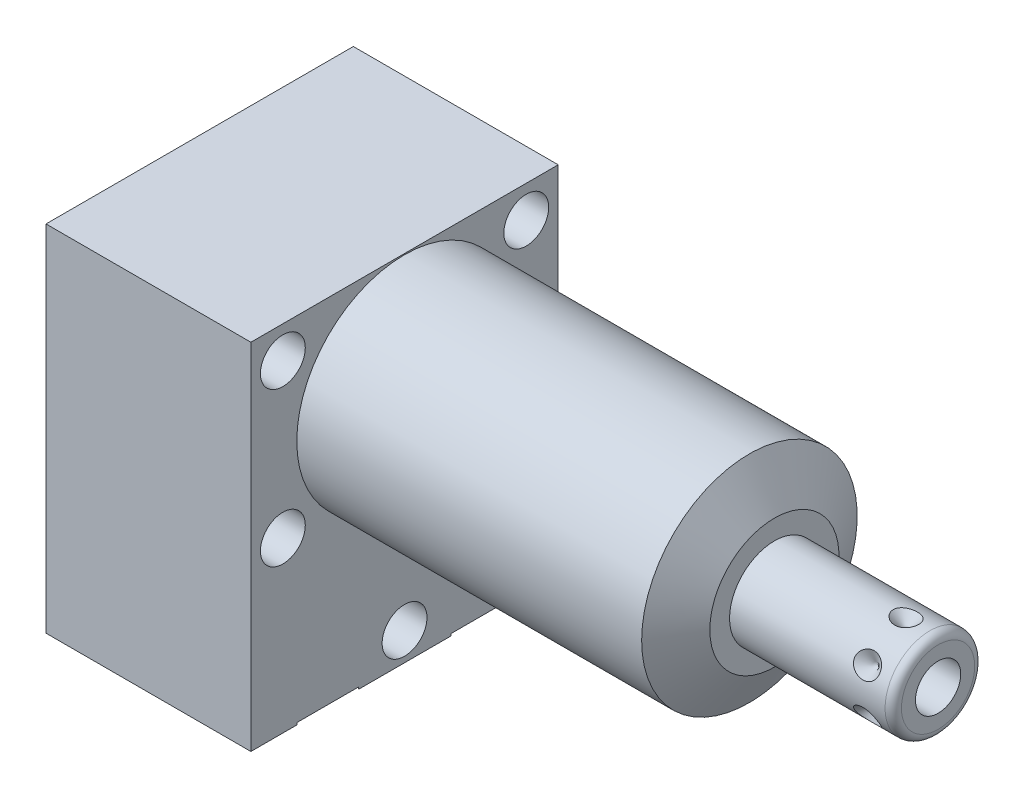
from build123d import *

# Parameters (mm, degrees)
SKETCH1_W           = 38.1
SKETCH1_H           = 43.942
EXTRUDE1_DEPTH      = 45.847
EXTRUDE1_DEPTH_BACK = 25.4
CUT_EXTRUDE1_REACH  = 47.847
SKETCH2_W           = 38.1
SKETCH2_H           = 43.942
SKETCH2_R           = 13.3604
SKETCH14_R          = 7.9375
CUT_EXTRUDE2_DEPTH  = 2.667
CIRPATTERN1_COUNT   = 6
HOLE1_D             = 5.5626
HOLE1_DEPTH         = 25.4
SKETCH18_R          = 1.7653


with BuildPart() as part:
    # Sketch1 → Extrude1 (new body, two sides)
    with BuildSketch(Plane(origin=(0, 0, 0), x_dir=(0, 0, -1), z_dir=(1, 0, 0))) as extrude1_sk:
        with Locations((0, -8.4836)):
            Rectangle(SKETCH1_W, SKETCH1_H)
    extrude(amount=EXTRUDE1_DEPTH)
    extrude(extrude1_sk.sketch, amount=-EXTRUDE1_DEPTH_BACK)

    # Sketch2 → Cut-Extrude1 (cut, up to next)
    with BuildSketch(Plane(origin=(0, 0, 0), x_dir=(0, 0, -1), z_dir=(1, 0, 0)), mode=Mode.PRIVATE) as cut_extrude1_sk1:
        with Locations((0, -8.4836)):
            Rectangle(SKETCH2_W, SKETCH2_H)
        Circle(SKETCH2_R, mode=Mode.SUBTRACT)
    cut_extrude1_tool1 = extrude(cut_extrude1_sk1.sketch, amount=CUT_EXTRUDE1_REACH, mode=Mode.PRIVATE) & part.part
    add(cut_extrude1_tool1.solids().sort_by_distance((0, 13.429241, 0))[0], mode=Mode.SUBTRACT)

    # Sketch3 → Cut-Revolve1 (revolve, cut)
    with BuildSketch(Plane.XY, mode=Mode.PRIVATE) as cut_revolve1_sk:
        Polygon((42.752748967, 13.3604), (45.847, 8.001), (45.847, 13.3604), align=None)
    revolve(cut_revolve1_sk.sketch.rotate(Axis((42.598036416, 0, 0), (1, 0, 0)), 90), axis=Axis((42.598036416, 0, 0), (1, 0, 0)), mode=Mode.SUBTRACT)  # turned: the seam where the file's is

    # S2D0002 → Cut-Revolve2 (revolve, cut)
    with BuildSketch(Plane(origin=(-22.733, -19.8374, 9.525), x_dir=(0, 1, 0), z_dir=(0, 0, 1)), mode=Mode.PRIVATE) as cut_revolve2_sk:
        Polygon((-0.8128, 0), (3.7338, 0), (3.293786662, -2.0701), (2.6416, -2.722286662), (2.6416, -13.97), (-0.8128, -13.97), align=None)
    revolve(cut_revolve2_sk.sketch.rotate(Axis((-8.0645, -20.6502, 9.525), (-1, 0, 0)), 90), axis=Axis((-8.0645, -20.6502, 9.525), (-1, 0, 0)), mode=Mode.SUBTRACT)  # turned: the seam where the file's is

    # Sketch5 → Cut-Revolve3 (revolve, cut)
    with BuildSketch(Plane(origin=(-22.733, -19.8374, -9.525), x_dir=(0, 1, 0), z_dir=(0, 0, 1)), mode=Mode.PRIVATE) as cut_revolve3_sk:
        Polygon((-0.8128, 0), (3.7338, 0), (3.293786662, -2.0701), (2.6416, -2.722286662), (2.6416, -13.97), (-0.8128, -13.97), align=None)
    revolve(cut_revolve3_sk.sketch.rotate(Axis((-8.0645, -20.6502, -9.525), (-1, 0, 0)), 90), axis=Axis((-8.0645, -20.6502, -9.525), (-1, 0, 0)), mode=Mode.SUBTRACT)  # turned: the seam where the file's is

    # Sketch14 → Cut-Extrude2 (cut)
    with BuildSketch(Plane.ZY.offset(25.4)):
        with Locations((-9.525, -20.6502)):
            Circle(SKETCH14_R)
        with Locations((9.525, -20.6502)):
            Circle(SKETCH14_R)
    extrude(amount=-CUT_EXTRUDE2_DEPTH, mode=Mode.SUBTRACT)

    # Sketch6 → Cut-Revolve4 (revolve, cut)
    with BuildSketch(Plane(origin=(-8.7376, -30.2006, 9.525), x_dir=(-1, 0, 0), z_dir=(0, 0, 1)), mode=Mode.PRIVATE) as cut_revolve4_sk:
        Polygon((6.18363, 0), (5.641036865, -2.5527), (4.97713, -3.216606865), (4.97713, -17.272), (0, -17.272), (0, 0), (0, 0.254), (9.52373, 0.254), (9.52373, 0), align=None)
    revolve(cut_revolve4_sk.sketch.rotate(Axis((-8.7376, -12.065, 9.525), (0, -1, 0)), 270), axis=Axis((-8.7376, -12.065, 9.525), (0, -1, 0)), mode=Mode.SUBTRACT)  # turned: the seam where the file's is

    # Sketch7 → Cut-Revolve5 (revolve, cut)
    with BuildSketch(Plane(origin=(-8.7376, -30.2006, -9.525), x_dir=(-1, 0, 0), z_dir=(0, 0, 1)), mode=Mode.PRIVATE) as cut_revolve5_sk:
        Polygon((6.1849, 0), (5.642306865, -2.5527), (4.9784, -3.216606865), (4.9784, -17.272), (0, -17.272), (0, 0), (0, 0.254), (9.52373, 0.254), (9.52373, 0), align=None)
    revolve(cut_revolve5_sk.sketch.rotate(Axis((-8.7376, -12.065, -9.525), (0, -1, 0)), 270), axis=Axis((-8.7376, -12.065, -9.525), (0, -1, 0)), mode=Mode.SUBTRACT)  # turned: the seam where the file's is

    # Sketch8 → Revolve1 (revolve)
    with BuildSketch(Plane.XY, mode=Mode.PRIVATE) as revolve1_sk:
        with BuildLine():
            Line((45.847, 0), (45.847, 5.55625))
            Line((45.847, 5.55625), (65.1256, 5.55625))
            ThreePointArc((65.1256, 5.55625), (65.84402049, 5.25867049), (66.1416, 4.54025))
            Line((66.1416, 4.54025), (66.1416, 0))
            Line((66.1416, 0), (45.847, 0))
        make_face()
    revolve(revolve1_sk.sketch.rotate(Axis((44.83227, 0, 0), (1, 0, 0)), 90), axis=Axis((44.83227, 0, 0), (1, 0, 0)))  # turned: the seam where the file's is

    # S2D0001 → Cut-Revolve6 (revolve, cut)
    with BuildSketch(Plane(origin=(66.1416, -2.8067, 0), x_dir=(0, -1, 0), z_dir=(0, 0, 1)), mode=Mode.PRIVATE) as cut_revolve6_sk:
        Polygon((0, 0), (0, -10.16), (-2.8067, -11.846435499), (-2.8067, 0), align=None)
    revolve(cut_revolve6_sk.sketch.rotate(Axis((53.702842726, 0, 0), (1, 0, 0)), 270), axis=Axis((53.702842726, 0, 0), (1, 0, 0)), mode=Mode.SUBTRACT)  # turned: the seam where the file's is

    # Sketch12 → Cut-Revolve7 (revolve, cut)
    with BuildSketch(Plane(origin=(62.1792, -5.55625, 0), x_dir=(-1, 0, 0), z_dir=(0, 0, 1)), mode=Mode.PRIVATE) as cut_revolve7_sk:
        Polygon((0, 0), (1.5875, 0), (0, -1.5875), align=None)
    cut_revolve7 = revolve(cut_revolve7_sk.sketch.rotate(Axis((62.1792, -2.12229387, 0), (0, -1, 0)), 90), axis=Axis((62.1792, -2.12229387, 0), (0, -1, 0)), mode=Mode.SUBTRACT)  # turned: the seam where the file's is

    # CirPattern1: Cut-Revolve7 ×6 about axis
    cirpattern1_axis = Axis((45.848, 0, 0), (-1, 0, 0))
    for i in range(1, CIRPATTERN1_COUNT):
        add(cut_revolve7.rotate(cirpattern1_axis, i * 360 / CIRPATTERN1_COUNT), mode=Mode.SUBTRACT)

    # Hole1
    with Locations(Plane(origin=(0, 0, 0), x_dir=(0, 0, -1), z_dir=(1, 0, 0))):
        with Locations((-15.0876, 9.525), (-15.0876, -9.525), (15.0876, 9.525), (15.0876, -9.525), (0, -26.9748)):
            Hole(HOLE1_D / 2, depth=HOLE1_DEPTH)


with BuildPart() as body_2:
    # Sketch18 → Revolve2 (revolve)
    with BuildSketch(Plane(origin=(-8.7376, -30.2006, 9.525), x_dir=(-1, 0, 0), z_dir=(0, 0, 1)), mode=Mode.PRIVATE) as revolve2_sk:
        with Locations((15.7607, -3.3782)):
            Circle(SKETCH18_R)
    revolve(revolve2_sk.sketch.rotate(Axis((-8.099075598, -20.6502, 9.525), (-1, 0, 0)), 90), axis=Axis((-8.099075598, -20.6502, 9.525), (-1, 0, 0)))  # turned: the seam where the file's is


solid = Compound([part.part, body_2.part])
